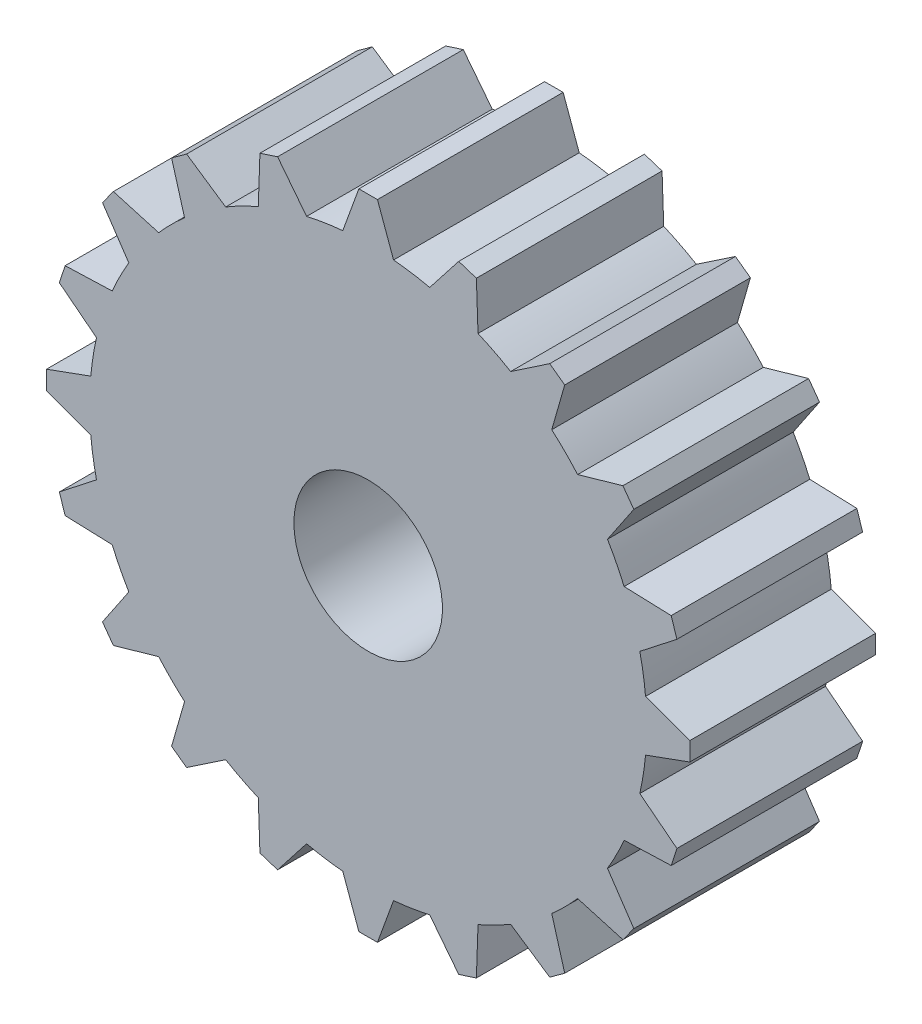
from build123d import *

# Parameters (mm, degrees)
IZIM1_R                     = 15
Y_KSEKLIK_EKSTR_ZYON1_DEPTH = 5
Y_KSEKLIK_EKSTR_ZYON2_DEPTH = 5
IZIM3_R                     = 4
KES_EKSTR_ZYON1_DEPTH       = 11


with BuildPart() as part:
    # Çizim1 → Yükseklik-Ekstrüzyon1 (new body, symmetric)
    with BuildSketch(Plane.XY):
        Circle(IZIM1_R)
    extrude(amount=Y_KSEKLIK_EKSTR_ZYON1_DEPTH, both=True)

    # Çizim2 → Yükseklik-Ekstrüzyon2 (add, symmetric)
    with BuildSketch(Plane.XY):
        Polygon((-2, 13.2), (2, 13.2), (0.5, 17.321216129), (-0.5, 17.321216129), align=None)
        Polygon((4.877021889, 16.627963967), (2.176911293, 13.171980004), (5.981137358, 11.935912026), (5.828078405, 16.318946973), align=None)
        Polygon((9.776646895, 14.307050838), (6.140731342, 11.85459483), (9.376799319, 9.503453821), (10.58566389, 13.719265586), align=None)
        Polygon((13.719265586, 10.58566389), (9.503453821, 9.376799319), (11.85459483, 6.140731342), (14.307050838, 9.776646895), align=None)
        Polygon((16.318946973, 5.828078405), (11.935912026, 5.981137358), (13.171980004, 2.176911293), (16.627963967, 4.877021889), align=None)
        Polygon((17.321216129, 0.5), (13.2, 2), (13.2, -2), (17.321216129, -0.5), align=None)
        Polygon((16.627963967, -4.877021889), (13.171980004, -2.176911293), (11.935912026, -5.981137358), (16.318946973, -5.828078405), align=None)
        Polygon((14.307050838, -9.776646895), (11.85459483, -6.140731342), (9.503453821, -9.376799319), (13.719265586, -10.58566389), align=None)
        Polygon((10.58566389, -13.719265586), (9.376799319, -9.503453821), (6.140731342, -11.85459483), (9.776646895, -14.307050838), align=None)
        Polygon((5.828078405, -16.318946973), (5.981137358, -11.935912026), (2.176911293, -13.171980004), (4.877021889, -16.627963967), align=None)
        Polygon((0.5, -17.321216129), (2, -13.2), (-2, -13.2), (-0.5, -17.321216129), align=None)
        Polygon((-4.877021889, -16.627963967), (-2.176911293, -13.171980004), (-5.981137358, -11.935912026), (-5.828078405, -16.318946973), align=None)
        Polygon((-9.776646895, -14.307050838), (-6.140731342, -11.85459483), (-9.376799319, -9.503453821), (-10.58566389, -13.719265586), align=None)
        Polygon((-13.719265586, -10.58566389), (-9.503453821, -9.376799319), (-11.85459483, -6.140731342), (-14.307050838, -9.776646895), align=None)
        Polygon((-16.318946973, -5.828078405), (-11.935912026, -5.981137358), (-13.171980004, -2.176911293), (-16.627963967, -4.877021889), align=None)
        Polygon((-17.321216129, -0.5), (-13.2, -2), (-13.2, 2), (-17.321216129, 0.5), align=None)
        Polygon((-16.627963967, 4.877021889), (-13.171980004, 2.176911293), (-11.935912026, 5.981137358), (-16.318946973, 5.828078405), align=None)
        Polygon((-14.307050838, 9.776646895), (-11.85459483, 6.140731342), (-9.503453821, 9.376799319), (-13.719265586, 10.58566389), align=None)
        Polygon((-10.58566389, 13.719265586), (-9.376799319, 9.503453821), (-6.140731342, 11.85459483), (-9.776646895, 14.307050838), align=None)
        Polygon((-5.828078405, 16.318946973), (-5.981137358, 11.935912026), (-2.176911293, 13.171980004), (-4.877021889, 16.627963967), align=None)
    extrude(amount=Y_KSEKLIK_EKSTR_ZYON2_DEPTH, both=True)

    # Çizim3 → Kes-Ekstrüzyon1 (cut, through all)
    with BuildSketch(Plane(origin=(0, 0, -5), x_dir=(-1, 0, 0), z_dir=(0, 0, -1))):
        Circle(IZIM3_R)
    extrude(amount=-KES_EKSTR_ZYON1_DEPTH, mode=Mode.SUBTRACT)


solid = part.part
